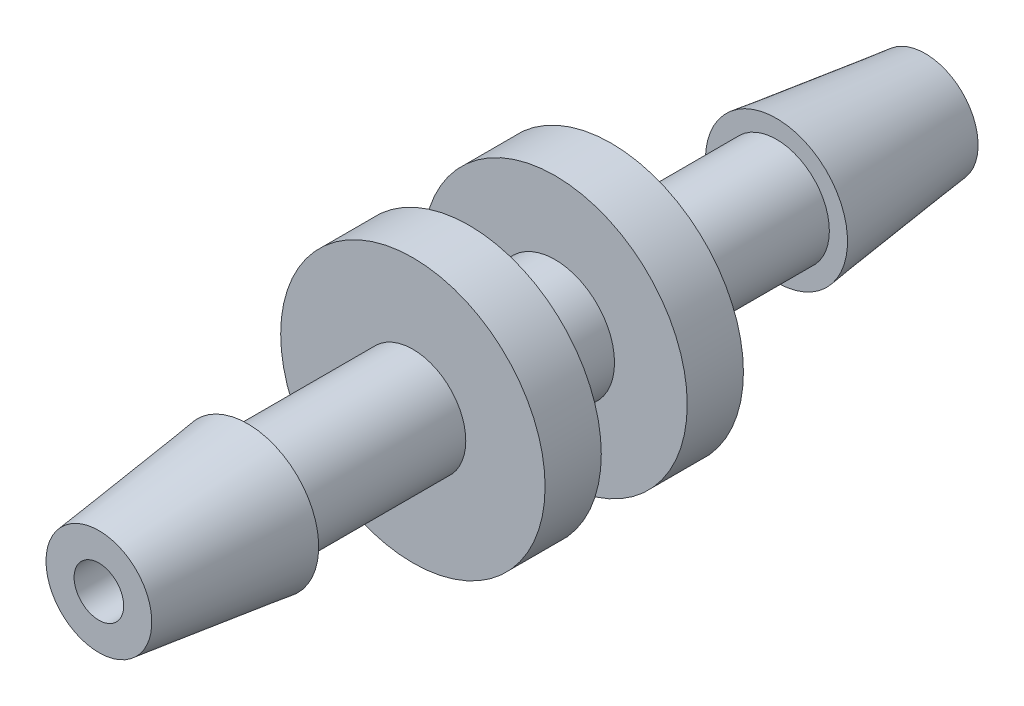
from build123d import *

# Parameters (mm, degrees)
SKETCH1_R           = 1.8
SKETCH1_R_2         = 0.75
BOSS_EXTRUDE1_DEPTH = 1.3
SKETCH2_R           = 4
SKETCH2_R_2         = 0.75
BOSS_EXTRUDE2_DEPTH = 1.7
SKETCH3_R           = 1.6
SKETCH3_R_2         = 0.75
BOSS_EXTRUDE3_DEPTH = 5


with BuildPart() as part:
    # Sketch1 → Boss-Extrude1 (new body)
    with BuildSketch(Plane.XY):
        Circle(SKETCH1_R)
        Circle(SKETCH1_R_2, mode=Mode.SUBTRACT)
    boss_extrude1 = extrude(amount=BOSS_EXTRUDE1_DEPTH)

    # Sketch2 → Boss-Extrude2 (add)
    with BuildSketch(Plane.XY.offset(1.3)):
        Circle(SKETCH2_R)
        Circle(SKETCH2_R_2, mode=Mode.SUBTRACT)
    boss_extrude2 = extrude(amount=BOSS_EXTRUDE2_DEPTH)

    # Sketch3 → Boss-Extrude3 (add)
    with BuildSketch(Plane.XY.offset(3)):
        Circle(SKETCH3_R)
        Circle(SKETCH3_R_2, mode=Mode.SUBTRACT)
    boss_extrude3 = extrude(amount=BOSS_EXTRUDE3_DEPTH)

    # Sketch5 → Revolve1 (revolve)
    with BuildSketch(Plane(origin=(0, 0, 0), x_dir=(1, 0, 0), z_dir=(0, 1, 0))):
        Polygon((0.75, -8), (0.75, -12.5), (1.6, -12.5), (2.15, -8), align=None)
    revolve1 = revolve(axis=Axis((0, 0, 0), (0, 0, 1)))

    # Mirror1: Boss-Extrude1, Boss-Extrude2, Boss-Extrude3, Revolve1 across plane
    add(boss_extrude1.mirror(Plane.XY))
    add(boss_extrude2.mirror(Plane.XY))
    add(boss_extrude3.mirror(Plane.XY))
    add(revolve1.mirror(Plane.XY))


solid = part.part
